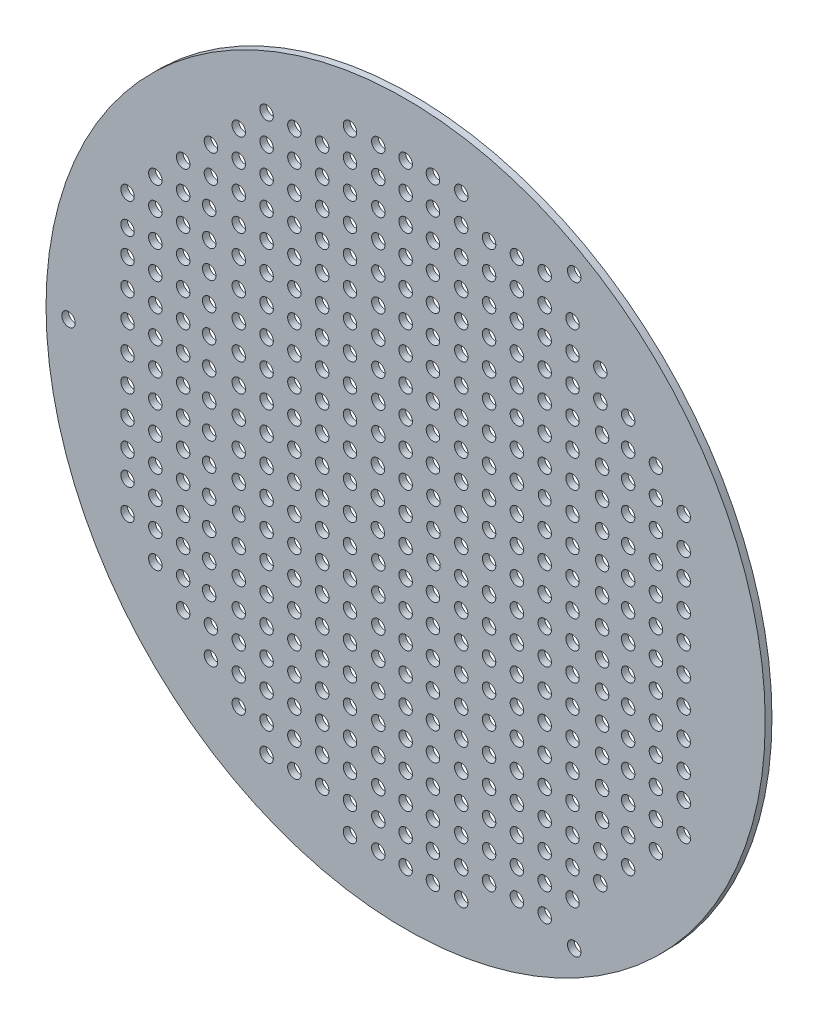
from build123d import *

# Parameters (mm, degrees)
CROQUIS1_R              = 160
CROQUIS1_R_2            = 3
SALIENTE_EXTRUIR1_DEPTH = 3
CROQUIS3_R              = 3
CROQUIS3_R_2            = 2.866176835
CROQUIS3_R_3            = 2.835716678
CORTAR_EXTRUIR1_DEPTH   = 4


with BuildPart() as part:
    # Croquis1 → Saliente-Extruir1 (new body)
    with BuildSketch(Plane.XY):
        Circle(CROQUIS1_R)
        with Locations((-150, 0)):
            Circle(CROQUIS1_R_2, mode=Mode.SUBTRACT)
        with Locations((75, 129.903810568)):
            Circle(CROQUIS1_R_2, mode=Mode.SUBTRACT)
        with Locations((75, -129.903810568)):
            Circle(CROQUIS1_R_2, mode=Mode.SUBTRACT)
    extrude(amount=SALIENTE_EXTRUIR1_DEPTH)

    # Croquis3 → Cortar-Extruir1 (cut, through all)
    with BuildSketch(Plane(origin=(0, 0, 0), x_dir=(-1, 0, 0), z_dir=(0, 0, -1))):
        with Locations((49.497474683, 49.497474683)):
            Circle(CROQUIS3_R)
        with Locations((37.123106012, 37.123106012)):
            Circle(CROQUIS3_R)
        with Locations((24.748737342, 24.748737342)):
            Circle(CROQUIS3_R)
        with Locations((12.374368671, 12.374368671)):
            Circle(CROQUIS3_R)
        Circle(CROQUIS3_R)
        with Locations((12.374368671, 0)):
            Circle(CROQUIS3_R)
        with Locations((24.748737342, 0)):
            Circle(CROQUIS3_R)
        with Locations((24.748737342, 12.374368671)):
            Circle(CROQUIS3_R)
        with Locations((37.123106012, 0)):
            Circle(CROQUIS3_R)
        with Locations((49.497474683, 0)):
            Circle(CROQUIS3_R)
        with Locations((37.123106012, 12.374368671)):
            Circle(CROQUIS3_R)
        with Locations((49.497474683, 12.374368671)):
            Circle(CROQUIS3_R)
        with Locations((37.123106012, 24.748737342)):
            Circle(CROQUIS3_R)
        with Locations((49.497474683, 24.748737342)):
            Circle(CROQUIS3_R)
        with Locations((49.497474683, 37.123106012)):
            Circle(CROQUIS3_R)
        with Locations((61.871843354, 61.871843354)):
            Circle(CROQUIS3_R)
        with Locations((74.246212025, 74.246212025)):
            Circle(CROQUIS3_R)
        with Locations((86.620580695, 86.620580695)):
            Circle(CROQUIS3_R)
        with Locations((87.409742312, 37.123106012)):
            Circle(CROQUIS3_R)
        with Locations((87.409742312, 49.497474683)):
            Circle(CROQUIS3_R)
        with Locations((87.409742312, 61.871843354)):
            Circle(CROQUIS3_R)
        with Locations((87.409742312, 74.246212025)):
            Circle(CROQUIS3_R)
        with Locations((61.871843354, 24.748737342)):
            Circle(CROQUIS3_R)
        with Locations((61.871843354, 12.374368671)):
            Circle(CROQUIS3_R)
        with Locations((61.871843354, 0)):
            Circle(CROQUIS3_R)
        with Locations((74.246212025, 0)):
            Circle(CROQUIS3_R)
        with Locations((74.246212025, 12.374368671)):
            Circle(CROQUIS3_R)
        with Locations((74.246212025, 24.748737342)):
            Circle(CROQUIS3_R)
        with Locations((87.409742312, 24.748737342)):
            Circle(CROQUIS3_R)
        with Locations((87.409742312, 12.374368671)):
            Circle(CROQUIS3_R)
        with Locations((87.409742312, 0)):
            Circle(CROQUIS3_R)
        with Locations((98.994949366, 74.246212025)):
            Circle(CROQUIS3_R)
        with Locations((98.994949366, 61.871843354)):
            Circle(CROQUIS3_R)
        with Locations((111.369318037, 61.871843354)):
            Circle(CROQUIS3_R)
        with Locations((111.369318037, 49.497474683)):
            Circle(CROQUIS3_R)
        with Locations((123.743686708, 48.347633285)):
            Circle(CROQUIS3_R)
        with Locations((98.994949366, 49.497474683)):
            Circle(CROQUIS3_R)
        with Locations((98.994949366, 37.123106012)):
            Circle(CROQUIS3_R)
        with Locations((98.994949366, 24.748737342)):
            Circle(CROQUIS3_R)
        with Locations((98.994949366, 12.374368671)):
            Circle(CROQUIS3_R)
        with Locations((98.994949366, 0)):
            Circle(CROQUIS3_R)
        with Locations((111.369318037, 0)):
            Circle(CROQUIS3_R)
        with Locations((111.369318037, 12.374368671)):
            Circle(CROQUIS3_R)
        with Locations((111.369318037, 24.748737342)):
            Circle(CROQUIS3_R)
        with Locations((111.369318037, 37.123106012)):
            Circle(CROQUIS3_R)
        with Locations((123.743686708, 37.123106012)):
            Circle(CROQUIS3_R)
        with Locations((123.743686708, 24.748737342)):
            Circle(CROQUIS3_R)
        with Locations((123.743686708, 12.374368671)):
            Circle(CROQUIS3_R)
        with Locations((123.743686708, 0)):
            Circle(CROQUIS3_R)
        with Locations((86.620580695, 98.994949366)):
            Circle(CROQUIS3_R)
        with Locations((74.246212025, 111.369318037)):
            Circle(CROQUIS3_R)
        with Locations((74.246212025, 86.620580695)):
            Circle(CROQUIS3_R)
        with Locations((61.871843354, 86.620580695)):
            Circle(CROQUIS3_R)
        with Locations((49.497474683, 61.871843354)):
            Circle(CROQUIS3_R)
        with Locations((49.497474683, 74.246212025)):
            Circle(CROQUIS3_R)
        with Locations((49.497474683, 86.620580695)):
            Circle(CROQUIS3_R)
        with Locations((49.497474683, 98.994949366)):
            Circle(CROQUIS3_R)
        with Locations((49.497474683, 111.369318037)):
            Circle(CROQUIS3_R)
        with Locations((37.123106012, 49.497474683)):
            Circle(CROQUIS3_R)
        with Locations((37.123106012, 61.871843354)):
            Circle(CROQUIS3_R)
        with Locations((37.123106012, 74.246212025)):
            Circle(CROQUIS3_R)
        with Locations((37.123106012, 86.620580695)):
            Circle(CROQUIS3_R)
        with Locations((37.123106012, 98.994949366)):
            Circle(CROQUIS3_R)
        with Locations((37.123106012, 111.369318037)):
            Circle(CROQUIS3_R)
        with Locations((37.123106012, 123.743686708)):
            Circle(CROQUIS3_R)
        with Locations((12.157457896, 123.743686708)):
            Circle(CROQUIS3_R)
        with Locations((12.157457896, 111.369318037)):
            Circle(CROQUIS3_R)
        with Locations((12.157457896, 98.994949366)):
            Circle(CROQUIS3_R)
        with Locations((12.157457896, 86.620580695)):
            Circle(CROQUIS3_R)
        with Locations((0, 111.369318037)):
            Circle(CROQUIS3_R)
        with Locations((0, 98.994949366)):
            Circle(CROQUIS3_R)
        with Locations((0, 86.620580695)):
            Circle(CROQUIS3_R)
        with Locations((74.246212025, 37.123106012)):
            Circle(CROQUIS3_R)
        with Locations((61.871843354, 37.123106012)):
            Circle(CROQUIS3_R)
        with Locations((74.246212025, 49.497474683)):
            Circle(CROQUIS3_R)
        with Locations((61.871843354, 49.497474683)):
            Circle(CROQUIS3_R)
        with Locations((74.246212025, 61.871843354)):
            Circle(CROQUIS3_R)
        with Locations((61.871843354, 111.369318037)):
            Circle(CROQUIS3_R)
        with Locations((61.871843354, 98.994949366)):
            Circle(CROQUIS3_R)
        with Locations((74.246212025, 98.994949366)):
            Circle(CROQUIS3_R)
        with Locations((61.871843354, 74.246212025)):
            Circle(CROQUIS3_R)
        with Locations((12.157457896, 74.246212025)):
            Circle(CROQUIS3_R)
        with Locations((0, 74.246212025)):
            Circle(CROQUIS3_R)
        with Locations((0, 49.497474683)):
            Circle(CROQUIS3_R)
        with Locations((12.157457896, 49.497474683)):
            Circle(CROQUIS3_R)
        with Locations((0, 61.871843354)):
            Circle(CROQUIS3_R)
        with Locations((12.157457896, 61.871843354)):
            Circle(CROQUIS3_R)
        with Locations((0, 12.374368671)):
            Circle(CROQUIS3_R)
        with Locations((12.157457896, 24.748737342)):
            Circle(CROQUIS3_R)
        with Locations((0, 24.748737342)):
            Circle(CROQUIS3_R)
        with Locations((0, 37.123106012)):
            Circle(CROQUIS3_R)
        with Locations((12.157457896, 37.123106012)):
            Circle(CROQUIS3_R)
        with Locations((24.748737342, 49.497474683)):
            Circle(CROQUIS3_R)
        with Locations((24.748737342, 37.123106012)):
            Circle(CROQUIS3_R)
        with Locations((24.748737342, 61.871843354)):
            Circle(CROQUIS3_R)
        with Locations((24.748737342, 74.246212025)):
            Circle(CROQUIS3_R)
        with Locations((24.748737342, 86.620580695)):
            Circle(CROQUIS3_R)
        with Locations((24.748737342, 98.994949366)):
            Circle(CROQUIS3_R)
        with Locations((24.748737342, 111.369318037)):
            Circle(CROQUIS3_R)
        with Locations((24.748737342, 123.743686708)):
            Circle(CROQUIS3_R)
        with Locations((123.743686708, 61.871843354)):
            Circle(CROQUIS3_R)
        with Locations((111.369318037, 74.246212025)):
            Circle(CROQUIS3_R)
        with Locations((98.994949366, 86.620580695)):
            Circle(CROQUIS3_R)
        with Locations((0, 123.743686708)):
            Circle(CROQUIS3_R)
        with Locations((-98.994949366, 86.620580695)):
            Circle(CROQUIS3_R)
        with Locations((-111.369318037, 74.246212025)):
            Circle(CROQUIS3_R)
        with Locations((-123.743686708, 61.871843354)):
            Circle(CROQUIS3_R)
        with Locations((-24.748737342, 123.743686708)):
            Circle(CROQUIS3_R)
        with Locations((-24.748737342, 111.369318037)):
            Circle(CROQUIS3_R)
        with Locations((-24.748737342, 98.994949366)):
            Circle(CROQUIS3_R)
        with Locations((-24.748737342, 86.620580695)):
            Circle(CROQUIS3_R)
        with Locations((-24.748737342, 74.246212025)):
            Circle(CROQUIS3_R)
        with Locations((-24.748737342, 61.871843354)):
            Circle(CROQUIS3_R)
        with Locations((-24.748737342, 37.123106012)):
            Circle(CROQUIS3_R)
        with Locations((-24.748737342, 49.497474683)):
            Circle(CROQUIS3_R)
        with Locations((-12.157457896, 37.123106012)):
            Circle(CROQUIS3_R)
        with Locations((-12.157457896, 24.748737342)):
            Circle(CROQUIS3_R)
        with Locations((-12.157457896, 61.871843354)):
            Circle(CROQUIS3_R)
        with Locations((-12.157457896, 49.497474683)):
            Circle(CROQUIS3_R)
        with Locations((-12.157457896, 74.246212025)):
            Circle(CROQUIS3_R)
        with Locations((-74.246212025, 61.871843354)):
            Circle(CROQUIS3_R)
        with Locations((-74.246212025, 49.497474683)):
            Circle(CROQUIS3_R)
        with Locations((-74.246212025, 37.123106012)):
            Circle(CROQUIS3_R)
        with Locations((-12.157457896, 86.620580695)):
            Circle(CROQUIS3_R)
        with Locations((-12.157457896, 98.994949366)):
            Circle(CROQUIS3_R)
        with Locations((-12.157457896, 111.369318037)):
            Circle(CROQUIS3_R)
        with Locations((-12.157457896, 123.743686708)):
            Circle(CROQUIS3_R)
        with Locations((-37.123106012, 123.743686708)):
            Circle(CROQUIS3_R)
        with Locations((-37.123106012, 111.369318037)):
            Circle(CROQUIS3_R)
        with Locations((-37.123106012, 98.994949366)):
            Circle(CROQUIS3_R)
        with Locations((-37.123106012, 86.620580695)):
            Circle(CROQUIS3_R)
        with Locations((-37.123106012, 74.246212025)):
            Circle(CROQUIS3_R)
        with Locations((-37.123106012, 61.871843354)):
            Circle(CROQUIS3_R)
        with Locations((-37.123106012, 49.497474683)):
            Circle(CROQUIS3_R)
        with Locations((-49.497474683, 111.369318037)):
            Circle(CROQUIS3_R)
        with Locations((-49.497474683, 98.994949366)):
            Circle(CROQUIS3_R)
        with Locations((-49.497474683, 86.620580695)):
            Circle(CROQUIS3_R)
        with Locations((-49.497474683, 74.246212025)):
            Circle(CROQUIS3_R)
        with Locations((-49.497474683, 61.871843354)):
            Circle(CROQUIS3_R)
        with Locations((-61.871843354, 111.369318037)):
            Circle(CROQUIS3_R)
        with Locations((-61.871843354, 98.994949366)):
            Circle(CROQUIS3_R)
        with Locations((-61.871843354, 74.246212025)):
            Circle(CROQUIS3_R)
        with Locations((-61.871843354, 86.620580695)):
            Circle(CROQUIS3_R)
        with Locations((-74.246212025, 86.620580695)):
            Circle(CROQUIS3_R)
        with Locations((-74.246212025, 111.369318037)):
            Circle(CROQUIS3_R)
        with Locations((-74.246212025, 98.994949366)):
            Circle(CROQUIS3_R)
        with Locations((-86.620580695, 98.994949366)):
            Circle(CROQUIS3_R)
        with Locations((-123.743686708, 0)):
            Circle(CROQUIS3_R)
        with Locations((-123.743686708, 12.374368671)):
            Circle(CROQUIS3_R)
        with Locations((-123.743686708, 24.748737342)):
            Circle(CROQUIS3_R)
        with Locations((-123.743686708, 37.123106012)):
            Circle(CROQUIS3_R)
        with Locations((-111.369318037, 37.123106012)):
            Circle(CROQUIS3_R)
        with Locations((-111.369318037, 24.748737342)):
            Circle(CROQUIS3_R)
        with Locations((-111.369318037, 12.374368671)):
            Circle(CROQUIS3_R)
        with Locations((-111.369318037, 0)):
            Circle(CROQUIS3_R)
        with Locations((-98.994949366, 0)):
            Circle(CROQUIS3_R)
        with Locations((-98.994949366, 12.374368671)):
            Circle(CROQUIS3_R)
        with Locations((-98.994949366, 24.748737342)):
            Circle(CROQUIS3_R)
        with Locations((-98.994949366, 37.123106012)):
            Circle(CROQUIS3_R)
        with Locations((-98.994949366, 49.497474683)):
            Circle(CROQUIS3_R)
        with Locations((-123.743686708, 48.347633285)):
            Circle(CROQUIS3_R)
        with Locations((-111.369318037, 49.497474683)):
            Circle(CROQUIS3_R)
        with Locations((-111.369318037, 61.871843354)):
            Circle(CROQUIS3_R)
        with Locations((-98.994949366, 61.871843354)):
            Circle(CROQUIS3_R)
        with Locations((-98.994949366, 74.246212025)):
            Circle(CROQUIS3_R)
        with Locations((-87.409742312, 0)):
            Circle(CROQUIS3_R)
        with Locations((-87.409742312, 12.374368671)):
            Circle(CROQUIS3_R)
        with Locations((-87.409742312, 24.748737342)):
            Circle(CROQUIS3_R)
        with Locations((-74.246212025, 24.748737342)):
            Circle(CROQUIS3_R)
        with Locations((-74.246212025, 12.374368671)):
            Circle(CROQUIS3_R)
        with Locations((-74.246212025, 0)):
            Circle(CROQUIS3_R)
        with Locations((-61.871843354, 0)):
            Circle(CROQUIS3_R)
        with Locations((-61.871843354, 12.374368671)):
            Circle(CROQUIS3_R)
        with Locations((-61.871843354, 24.748737342)):
            Circle(CROQUIS3_R)
        with Locations((-87.409742312, 74.246212025)):
            Circle(CROQUIS3_R)
        with Locations((-87.409742312, 61.871843354)):
            Circle(CROQUIS3_R)
        with Locations((-87.409742312, 49.497474683)):
            Circle(CROQUIS3_R)
        with Locations((-61.871843354, 49.497474683)):
            Circle(CROQUIS3_R)
        with Locations((-87.409742312, 37.123106012)):
            Circle(CROQUIS3_R)
        with Locations((-61.871843354, 37.123106012)):
            Circle(CROQUIS3_R_2)
        with Locations((-86.620580695, 86.620580695)):
            Circle(CROQUIS3_R)
        with Locations((-74.246212025, 74.246212025)):
            Circle(CROQUIS3_R)
        with Locations((-61.871843354, 61.871843354)):
            Circle(CROQUIS3_R)
        with Locations((-49.497474683, 37.123106012)):
            Circle(CROQUIS3_R)
        with Locations((-49.497474683, 24.748737342)):
            Circle(CROQUIS3_R)
        with Locations((-37.123106012, 24.748737342)):
            Circle(CROQUIS3_R)
        with Locations((-49.497474683, 12.374368671)):
            Circle(CROQUIS3_R)
        with Locations((-37.123106012, 12.374368671)):
            Circle(CROQUIS3_R)
        with Locations((-49.497474683, 0)):
            Circle(CROQUIS3_R)
        with Locations((-37.123106012, 0)):
            Circle(CROQUIS3_R)
        with Locations((-24.748737342, 12.374368671)):
            Circle(CROQUIS3_R)
        with Locations((-24.748737342, 0)):
            Circle(CROQUIS3_R)
        with Locations((-12.374368671, 0)):
            Circle(CROQUIS3_R)
        with Locations((-12.374368671, 12.374368671)):
            Circle(CROQUIS3_R)
        with Locations((-24.748737342, 24.748737342)):
            Circle(CROQUIS3_R)
        with Locations((-37.123106012, 37.123106012)):
            Circle(CROQUIS3_R)
        with Locations((-49.497474683, 49.497474683)):
            Circle(CROQUIS3_R)
        with Locations((-24.748737342, -12.374368671)):
            Circle(CROQUIS3_R)
        with Locations((-37.123106012, -12.374368671)):
            Circle(CROQUIS3_R)
        with Locations((-49.497474683, -12.374368671)):
            Circle(CROQUIS3_R)
        with Locations((-37.123106012, -24.748737342)):
            Circle(CROQUIS3_R)
        with Locations((-49.497474683, -24.748737342)):
            Circle(CROQUIS3_R)
        with Locations((-49.497474683, -37.123106012)):
            Circle(CROQUIS3_R)
        with Locations((-61.871843354, -61.871843354)):
            Circle(CROQUIS3_R)
        with Locations((-74.246212025, -74.246212025)):
            Circle(CROQUIS3_R)
        with Locations((-86.620580695, -86.620580695)):
            Circle(CROQUIS3_R)
        with Locations((-87.409742312, -37.123106012)):
            Circle(CROQUIS3_R)
        with Locations((-87.409742312, -49.497474683)):
            Circle(CROQUIS3_R)
        with Locations((-87.409742312, -61.871843354)):
            Circle(CROQUIS3_R)
        with Locations((-87.409742312, -74.246212025)):
            Circle(CROQUIS3_R)
        with Locations((-61.871843354, -24.748737342)):
            Circle(CROQUIS3_R)
        with Locations((-61.871843354, -12.374368671)):
            Circle(CROQUIS3_R)
        with Locations((-74.246212025, -12.374368671)):
            Circle(CROQUIS3_R)
        with Locations((-74.246212025, -24.748737342)):
            Circle(CROQUIS3_R)
        with Locations((-87.409742312, -24.748737342)):
            Circle(CROQUIS3_R)
        with Locations((-87.409742312, -12.374368671)):
            Circle(CROQUIS3_R)
        with Locations((-98.994949366, -74.246212025)):
            Circle(CROQUIS3_R)
        with Locations((-98.994949366, -61.871843354)):
            Circle(CROQUIS3_R)
        with Locations((-111.369318037, -61.871843354)):
            Circle(CROQUIS3_R)
        with Locations((-111.369318037, -49.497474683)):
            Circle(CROQUIS3_R)
        with Locations((-123.743686708, -48.347633285)):
            Circle(CROQUIS3_R)
        with Locations((-98.994949366, -49.497474683)):
            Circle(CROQUIS3_R)
        with Locations((-98.994949366, -37.123106012)):
            Circle(CROQUIS3_R)
        with Locations((-98.994949366, -24.748737342)):
            Circle(CROQUIS3_R)
        with Locations((-98.994949366, -12.374368671)):
            Circle(CROQUIS3_R)
        with Locations((-111.369318037, -12.374368671)):
            Circle(CROQUIS3_R)
        with Locations((-111.369318037, -24.748737342)):
            Circle(CROQUIS3_R)
        with Locations((-111.369318037, -37.123106012)):
            Circle(CROQUIS3_R)
        with Locations((-123.743686708, -37.123106012)):
            Circle(CROQUIS3_R)
        with Locations((-123.743686708, -24.748737342)):
            Circle(CROQUIS3_R)
        with Locations((-123.743686708, -12.374368671)):
            Circle(CROQUIS3_R)
        with Locations((-86.620580695, -98.994949366)):
            Circle(CROQUIS3_R)
        with Locations((-74.246212025, -111.369318037)):
            Circle(CROQUIS3_R)
        with Locations((-74.246212025, -86.620580695)):
            Circle(CROQUIS3_R)
        with Locations((-61.871843354, -86.620580695)):
            Circle(CROQUIS3_R)
        with Locations((-49.497474683, -61.871843354)):
            Circle(CROQUIS3_R)
        with Locations((-49.497474683, -74.246212025)):
            Circle(CROQUIS3_R)
        with Locations((-49.497474683, -86.620580695)):
            Circle(CROQUIS3_R)
        with Locations((-49.497474683, -98.994949366)):
            Circle(CROQUIS3_R)
        with Locations((-49.497474683, -111.369318037)):
            Circle(CROQUIS3_R)
        with Locations((-37.123106012, -49.497474683)):
            Circle(CROQUIS3_R)
        with Locations((-37.123106012, -61.871843354)):
            Circle(CROQUIS3_R)
        with Locations((-37.123106012, -74.246212025)):
            Circle(CROQUIS3_R)
        with Locations((-37.123106012, -86.620580695)):
            Circle(CROQUIS3_R)
        with Locations((-37.123106012, -98.994949366)):
            Circle(CROQUIS3_R)
        with Locations((-37.123106012, -111.369318037)):
            Circle(CROQUIS3_R)
        with Locations((-37.123106012, -123.743686708)):
            Circle(CROQUIS3_R)
        with Locations((-12.157457896, -123.743686708)):
            Circle(CROQUIS3_R)
        with Locations((-12.157457896, -111.369318037)):
            Circle(CROQUIS3_R)
        with Locations((-12.157457896, -98.994949366)):
            Circle(CROQUIS3_R)
        with Locations((-12.157457896, -86.620580695)):
            Circle(CROQUIS3_R)
        with Locations((-74.246212025, -37.123106012)):
            Circle(CROQUIS3_R)
        with Locations((-61.871843354, -37.123106012)):
            Circle(CROQUIS3_R)
        with Locations((-74.246212025, -49.497474683)):
            Circle(CROQUIS3_R)
        with Locations((-61.871843354, -49.497474683)):
            Circle(CROQUIS3_R)
        with Locations((-74.246212025, -61.871843354)):
            Circle(CROQUIS3_R)
        with Locations((-61.871843354, -111.369318037)):
            Circle(CROQUIS3_R)
        with Locations((-61.871843354, -98.994949366)):
            Circle(CROQUIS3_R)
        with Locations((-74.246212025, -98.994949366)):
            Circle(CROQUIS3_R)
        with Locations((-61.871843354, -74.246212025)):
            Circle(CROQUIS3_R)
        with Locations((-12.157457896, -74.246212025)):
            Circle(CROQUIS3_R)
        with Locations((-12.157457896, -49.497474683)):
            Circle(CROQUIS3_R)
        with Locations((-12.157457896, -61.871843354)):
            Circle(CROQUIS3_R)
        with Locations((-24.748737342, -49.497474683)):
            Circle(CROQUIS3_R)
        with Locations((-24.748737342, -61.871843354)):
            Circle(CROQUIS3_R)
        with Locations((-24.748737342, -74.246212025)):
            Circle(CROQUIS3_R)
        with Locations((-24.748737342, -86.620580695)):
            Circle(CROQUIS3_R)
        with Locations((-24.748737342, -98.994949366)):
            Circle(CROQUIS3_R)
        with Locations((-24.748737342, -111.369318037)):
            Circle(CROQUIS3_R)
        with Locations((-24.748737342, -123.743686708)):
            Circle(CROQUIS3_R)
        with Locations((-123.743686708, -61.871843354)):
            Circle(CROQUIS3_R)
        with Locations((-111.369318037, -74.246212025)):
            Circle(CROQUIS3_R)
        with Locations((-98.994949366, -86.620580695)):
            Circle(CROQUIS3_R)
        with Locations((0, -123.743686708)):
            Circle(CROQUIS3_R)
        with Locations((98.994949366, -86.620580695)):
            Circle(CROQUIS3_R)
        with Locations((111.369318037, -74.246212025)):
            Circle(CROQUIS3_R)
        with Locations((123.743686708, -61.871843354)):
            Circle(CROQUIS3_R)
        with Locations((24.748737342, -123.743686708)):
            Circle(CROQUIS3_R)
        with Locations((24.748737342, -111.369318037)):
            Circle(CROQUIS3_R)
        with Locations((24.748737342, -98.994949366)):
            Circle(CROQUIS3_R)
        with Locations((24.748737342, -86.620580695)):
            Circle(CROQUIS3_R)
        with Locations((24.748737342, -74.246212025)):
            Circle(CROQUIS3_R)
        with Locations((24.748737342, -61.871843354)):
            Circle(CROQUIS3_R)
        with Locations((24.748737342, -37.123106012)):
            Circle(CROQUIS3_R)
        with Locations((24.748737342, -49.497474683)):
            Circle(CROQUIS3_R)
        with Locations((12.157457896, -37.123106012)):
            Circle(CROQUIS3_R)
        with Locations((0, -37.123106012)):
            Circle(CROQUIS3_R)
        with Locations((0, -24.748737342)):
            Circle(CROQUIS3_R)
        with Locations((12.157457896, -24.748737342)):
            Circle(CROQUIS3_R)
        with Locations((-12.157457896, -37.123106012)):
            Circle(CROQUIS3_R)
        with Locations((-24.748737342, -37.123106012)):
            Circle(CROQUIS3_R)
        with Locations((-12.157457896, -24.748737342)):
            Circle(CROQUIS3_R)
        with Locations((0, -12.374368671)):
            Circle(CROQUIS3_R)
        with Locations((12.157457896, -61.871843354)):
            Circle(CROQUIS3_R)
        with Locations((0, -61.871843354)):
            Circle(CROQUIS3_R)
        with Locations((12.157457896, -49.497474683)):
            Circle(CROQUIS3_R)
        with Locations((0, -49.497474683)):
            Circle(CROQUIS3_R)
        with Locations((0, -74.246212025)):
            Circle(CROQUIS3_R)
        with Locations((12.157457896, -74.246212025)):
            Circle(CROQUIS3_R)
        with Locations((74.246212025, -61.871843354)):
            Circle(CROQUIS3_R)
        with Locations((61.871843354, -37.123106012)):
            Circle(CROQUIS3_R)
        with Locations((0, -86.620580695)):
            Circle(CROQUIS3_R)
        with Locations((0, -98.994949366)):
            Circle(CROQUIS3_R)
        with Locations((0, -111.369318037)):
            Circle(CROQUIS3_R)
        with Locations((12.157457896, -86.620580695)):
            Circle(CROQUIS3_R)
        with Locations((12.157457896, -98.994949366)):
            Circle(CROQUIS3_R)
        with Locations((12.157457896, -111.369318037)):
            Circle(CROQUIS3_R)
        with Locations((12.157457896, -123.743686708)):
            Circle(CROQUIS3_R)
        with Locations((37.123106012, -123.743686708)):
            Circle(CROQUIS3_R)
        with Locations((37.123106012, -111.369318037)):
            Circle(CROQUIS3_R)
        with Locations((37.123106012, -98.994949366)):
            Circle(CROQUIS3_R)
        with Locations((37.123106012, -86.620580695)):
            Circle(CROQUIS3_R)
        with Locations((37.123106012, -74.246212025)):
            Circle(CROQUIS3_R)
        with Locations((37.123106012, -61.871843354)):
            Circle(CROQUIS3_R)
        with Locations((37.123106012, -49.497474683)):
            Circle(CROQUIS3_R)
        with Locations((49.497474683, -111.369318037)):
            Circle(CROQUIS3_R)
        with Locations((49.497474683, -98.994949366)):
            Circle(CROQUIS3_R)
        with Locations((49.497474683, -86.620580695)):
            Circle(CROQUIS3_R)
        with Locations((49.497474683, -74.246212025)):
            Circle(CROQUIS3_R)
        with Locations((49.497474683, -61.871843354)):
            Circle(CROQUIS3_R)
        with Locations((61.871843354, -111.369318037)):
            Circle(CROQUIS3_R)
        with Locations((61.871843354, -98.994949366)):
            Circle(CROQUIS3_R)
        with Locations((61.871843354, -74.246212025)):
            Circle(CROQUIS3_R)
        with Locations((61.871843354, -86.620580695)):
            Circle(CROQUIS3_R)
        with Locations((74.246212025, -86.620580695)):
            Circle(CROQUIS3_R)
        with Locations((74.246212025, -111.369318037)):
            Circle(CROQUIS3_R)
        with Locations((74.246212025, -98.994949366)):
            Circle(CROQUIS3_R)
        with Locations((86.620580695, -98.994949366)):
            Circle(CROQUIS3_R)
        with Locations((123.743686708, -12.374368671)):
            Circle(CROQUIS3_R)
        with Locations((123.743686708, -24.748737342)):
            Circle(CROQUIS3_R)
        with Locations((123.743686708, -37.123106012)):
            Circle(CROQUIS3_R)
        with Locations((111.369318037, -37.123106012)):
            Circle(CROQUIS3_R)
        with Locations((111.369318037, -24.748737342)):
            Circle(CROQUIS3_R)
        with Locations((111.369318037, -12.374368671)):
            Circle(CROQUIS3_R)
        with Locations((98.994949366, -12.374368671)):
            Circle(CROQUIS3_R)
        with Locations((98.994949366, -24.748737342)):
            Circle(CROQUIS3_R)
        with Locations((98.994949366, -37.123106012)):
            Circle(CROQUIS3_R)
        with Locations((98.994949366, -49.497474683)):
            Circle(CROQUIS3_R)
        with Locations((123.743686708, -48.347633285)):
            Circle(CROQUIS3_R)
        with Locations((111.369318037, -49.497474683)):
            Circle(CROQUIS3_R)
        with Locations((111.369318037, -61.871843354)):
            Circle(CROQUIS3_R)
        with Locations((98.994949366, -61.871843354)):
            Circle(CROQUIS3_R)
        with Locations((98.994949366, -74.246212025)):
            Circle(CROQUIS3_R)
        with Locations((87.409742312, -12.374368671)):
            Circle(CROQUIS3_R)
        with Locations((87.409742312, -24.748737342)):
            Circle(CROQUIS3_R)
        with Locations((74.246212025, -24.748737342)):
            Circle(CROQUIS3_R)
        with Locations((74.246212025, -12.374368671)):
            Circle(CROQUIS3_R)
        with Locations((61.871843354, -12.374368671)):
            Circle(CROQUIS3_R)
        with Locations((61.871843354, -24.748737342)):
            Circle(CROQUIS3_R)
        with Locations((87.409742312, -74.246212025)):
            Circle(CROQUIS3_R)
        with Locations((87.409742312, -61.871843354)):
            Circle(CROQUIS3_R)
        with Locations((87.409742312, -49.497474683)):
            Circle(CROQUIS3_R)
        with Locations((74.246212025, -49.497474683)):
            Circle(CROQUIS3_R)
        with Locations((61.871843354, -49.497474683)):
            Circle(CROQUIS3_R)
        with Locations((87.409742312, -37.123106012)):
            Circle(CROQUIS3_R)
        with Locations((74.246212025, -37.123106012)):
            Circle(CROQUIS3_R_3)
        with Locations((86.620580695, -86.620580695)):
            Circle(CROQUIS3_R)
        with Locations((74.246212025, -74.246212025)):
            Circle(CROQUIS3_R)
        with Locations((61.871843354, -61.871843354)):
            Circle(CROQUIS3_R)
        with Locations((49.497474683, -37.123106012)):
            Circle(CROQUIS3_R)
        with Locations((49.497474683, -24.748737342)):
            Circle(CROQUIS3_R)
        with Locations((37.123106012, -24.748737342)):
            Circle(CROQUIS3_R)
        with Locations((49.497474683, -12.374368671)):
            Circle(CROQUIS3_R)
        with Locations((37.123106012, -12.374368671)):
            Circle(CROQUIS3_R)
        with Locations((24.748737342, -12.374368671)):
            Circle(CROQUIS3_R)
        with Locations((-12.374368671, -12.374368671)):
            Circle(CROQUIS3_R)
        with Locations((-24.748737342, -24.748737342)):
            Circle(CROQUIS3_R)
        with Locations((-37.123106012, -37.123106012)):
            Circle(CROQUIS3_R)
        with Locations((-49.497474683, -49.497474683)):
            Circle(CROQUIS3_R)
        with Locations((12.374368671, -12.374368671)):
            Circle(CROQUIS3_R)
        with Locations((24.748737342, -24.748737342)):
            Circle(CROQUIS3_R)
        with Locations((37.123106012, -37.123106012)):
            Circle(CROQUIS3_R)
        with Locations((49.497474683, -49.497474683)):
            Circle(CROQUIS3_R)
        with Locations((49.497474683, 123.743686708)):
            Circle(CROQUIS3_R)
        with Locations((61.871843354, 123.743686708)):
            Circle(CROQUIS3_R)
        with Locations((24.748737342, 136.118055378)):
            Circle(CROQUIS3_R)
        with Locations((12.157457896, 136.118055378)):
            Circle(CROQUIS3_R)
        with Locations((0, 136.118055378)):
            Circle(CROQUIS3_R)
        with Locations((-24.748737342, 136.118055378)):
            Circle(CROQUIS3_R)
        with Locations((-12.157457896, 136.118055378)):
            Circle(CROQUIS3_R)
        with Locations((-49.497474683, 123.743686708)):
            Circle(CROQUIS3_R)
        with Locations((-61.871843354, 123.743686708)):
            Circle(CROQUIS3_R)
        with Locations((-61.871843354, -123.743686708)):
            Circle(CROQUIS3_R)
        with Locations((-49.497474683, -123.743686708)):
            Circle(CROQUIS3_R)
        with Locations((61.871843354, -123.743686708)):
            Circle(CROQUIS3_R)
        with Locations((49.497474683, -123.743686708)):
            Circle(CROQUIS3_R)
        with Locations((24.748737342, -136.118055378)):
            Circle(CROQUIS3_R)
        with Locations((12.157457896, -136.118055378)):
            Circle(CROQUIS3_R)
        with Locations((0, -136.118055378)):
            Circle(CROQUIS3_R)
        with Locations((-12.157457896, -136.118055378)):
            Circle(CROQUIS3_R)
        with Locations((-24.748737342, -136.118055378)):
            Circle(CROQUIS3_R)
    extrude(amount=-CORTAR_EXTRUIR1_DEPTH, mode=Mode.SUBTRACT)


solid = part.part
